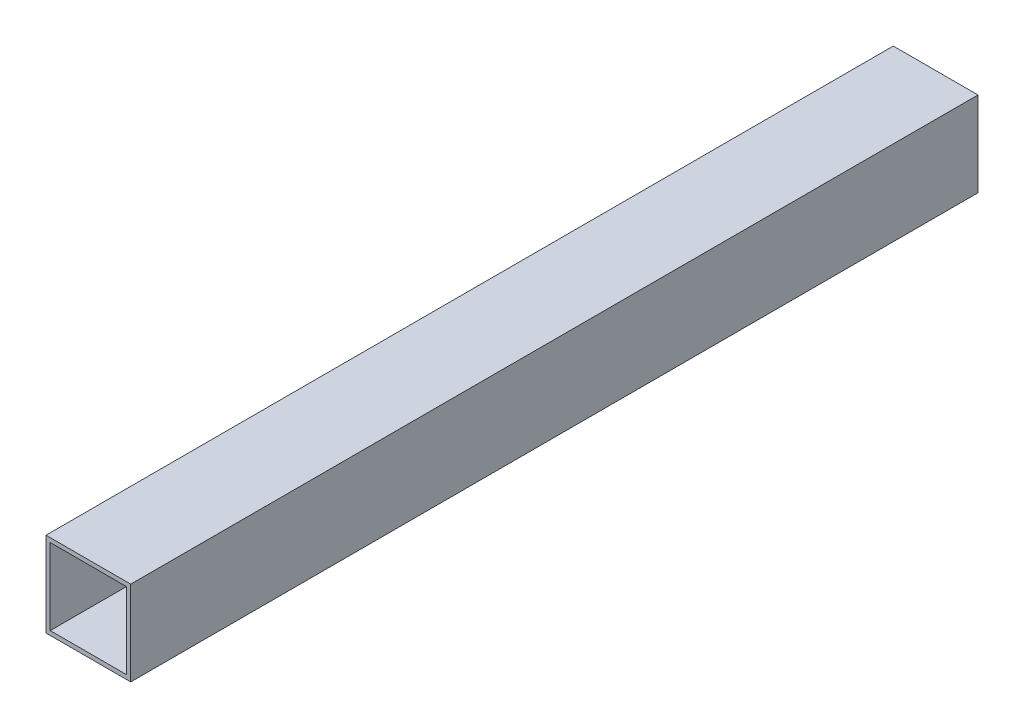
from build123d import *

# Parameters (mm, degrees)
SKETCH1_W           = 100
SKETCH1_H           = 100
SKETCH1_W_2         = 90
SKETCH1_H_2         = 90
BOSS_EXTRUDE1_DEPTH = 500


with BuildPart() as part:
    # Sketch1 → Boss-Extrude1 (new body, symmetric)
    with BuildSketch(Plane.XY):
        Rectangle(SKETCH1_W, SKETCH1_H)
        Rectangle(SKETCH1_W_2, SKETCH1_H_2, mode=Mode.SUBTRACT)
    extrude(amount=BOSS_EXTRUDE1_DEPTH, both=True)


solid = part.part
